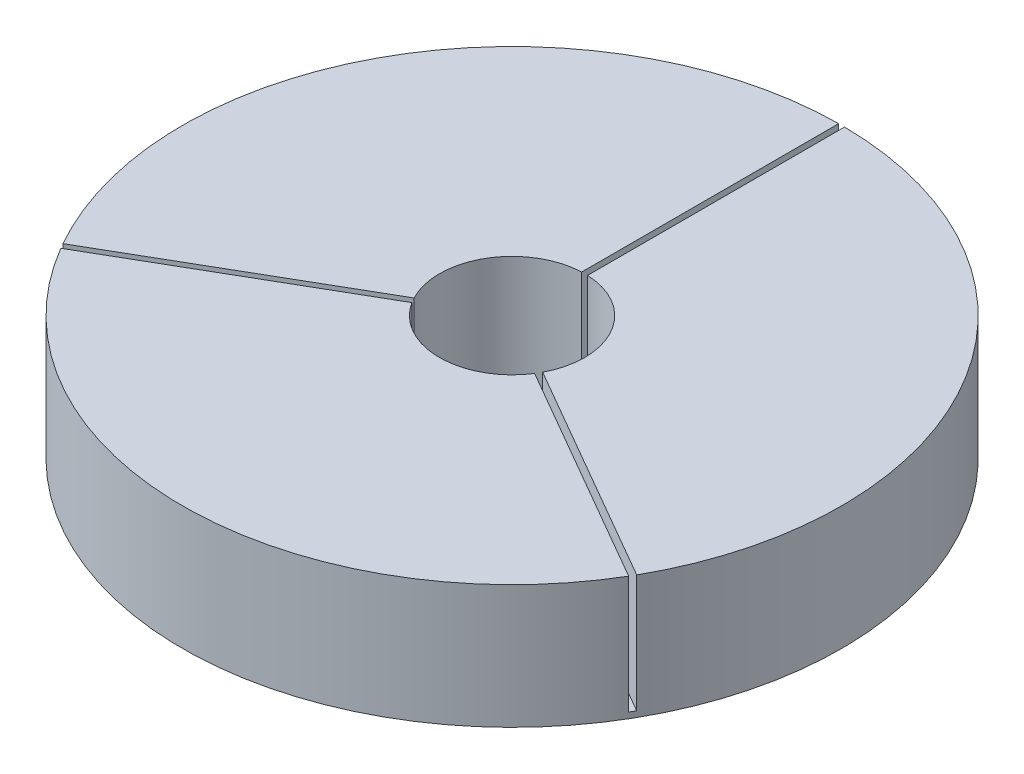
from build123d import *

# Parameters (mm, degrees)
BOSS_EXTRUDE1_DEPTH   = 127
BOSS_EXTRUDE1_2_DEPTH = 127
BOSS_EXTRUDE1_3_DEPTH = 127
SKETCH3_R             = 355.614173825
BOSS_EXTRUDE2_DEPTH   = 6.35


with BuildPart() as part:
    # Sketch2 → Boss-Extrude1 (new body)
    with BuildSketch(Plane(origin=(0, 0, 0), x_dir=(1, 0, 0), z_dir=(0, 1, 0))):
        with BuildLine():
            ThreePointArc((-3.175, 355.6), (-307.970908478, 177.807086912), (-309.546133586, -175.050369343))
            Line((-309.546133586, -175.050369343), (-69.392656087, -36.397694462))
            ThreePointArc((-69.392656087, -36.397694462), (-67.860884615, 39.1795), (-3.175, 78.294650239))
            Line((-3.175, 78.294650239), (-3.175, 355.6))
        make_face()
    extrude(amount=BOSS_EXTRUDE1_DEPTH)



with BuildPart() as body_2:
    # Sketch2 → Boss-Extrude1 2 (new body)
    with BuildSketch(Plane(origin=(0, 0, 0), x_dir=(1, 0, 0), z_dir=(0, 1, 0))):
        with BuildLine():
            Line((69.392656087, -36.397694462), (309.546133586, -175.050369343))
            ThreePointArc((309.546133586, -175.050369343), (343.904371287, -90.505381247), (355.614173825, 0))
            ThreePointArc((355.614173825, 0), (252.577231384, 250.332144983), (3.175, 355.6))
            Line((3.175, 355.6), (3.175, 78.294650239))
            ThreePointArc((3.175, 78.294650239), (56.519566108, 54.274041014), (78.359, 0))
            ThreePointArc((78.359, 0), (76.084400567, -18.74291523), (69.392656087, -36.397694462))
        make_face()
    extrude(amount=BOSS_EXTRUDE1_2_DEPTH)


with BuildPart() as body_3:
    # Sketch2 → Boss-Extrude1 3 (new body)
    with BuildSketch(Plane(origin=(0, 0, 0), x_dir=(1, 0, 0), z_dir=(0, 1, 0))):
        with BuildLine():
            ThreePointArc((-306.371133586, -180.549630657), (0, -355.614173825), (306.371133586, -180.549630657))
            Line((306.371133586, -180.549630657), (66.217656087, -41.896955776))
            ThreePointArc((66.217656087, -41.896955776), (0, -78.359), (-66.217656087, -41.896955776))
            Line((-66.217656087, -41.896955776), (-306.371133586, -180.549630657))
        make_face()
    extrude(amount=BOSS_EXTRUDE1_3_DEPTH)


with BuildPart() as part_1:
    add(part.part)

    add(body_2.part)  # Boss-Extrude2 merges body 2

    add(body_3.part)  # Boss-Extrude2 merges body 3
    # Sketch3 → Boss-Extrude2 (add)
    with BuildSketch(Plane.XZ):
        Circle(SKETCH3_R)
    extrude(amount=BOSS_EXTRUDE2_DEPTH)


solid = part_1.part
